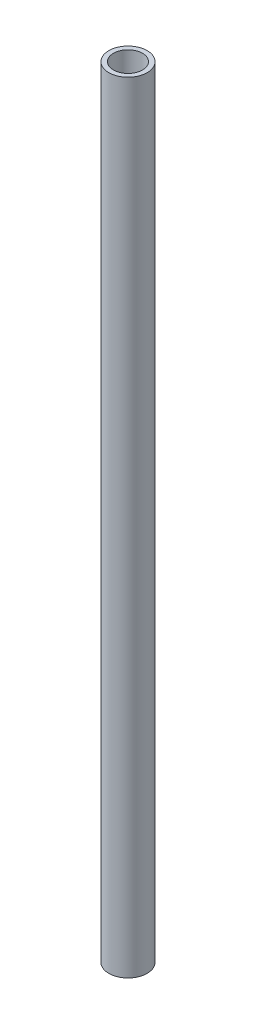
from build123d import *

# Parameters (mm, degrees)
SKETCH1_R           = 13.5
SKETCH1_R_2         = 10.25
BOSS_EXTRUDE1_DEPTH = 550


with BuildPart() as part:
    # Sketch1 → Boss-Extrude1 (new body)
    with BuildSketch(Plane(origin=(0, 0, 0), x_dir=(1, 0, 0), z_dir=(0, 1, 0))):
        with Locations(Location((0, 0, 0), (0, 0, 270))):  # turned: the seam where the file's is
            Circle(SKETCH1_R)
        with Locations(Location((0, 0, 0), (0, 0, 270))):  # turned: the seam where the file's is
            Circle(SKETCH1_R_2, mode=Mode.SUBTRACT)
    extrude(amount=BOSS_EXTRUDE1_DEPTH)


solid = part.part
